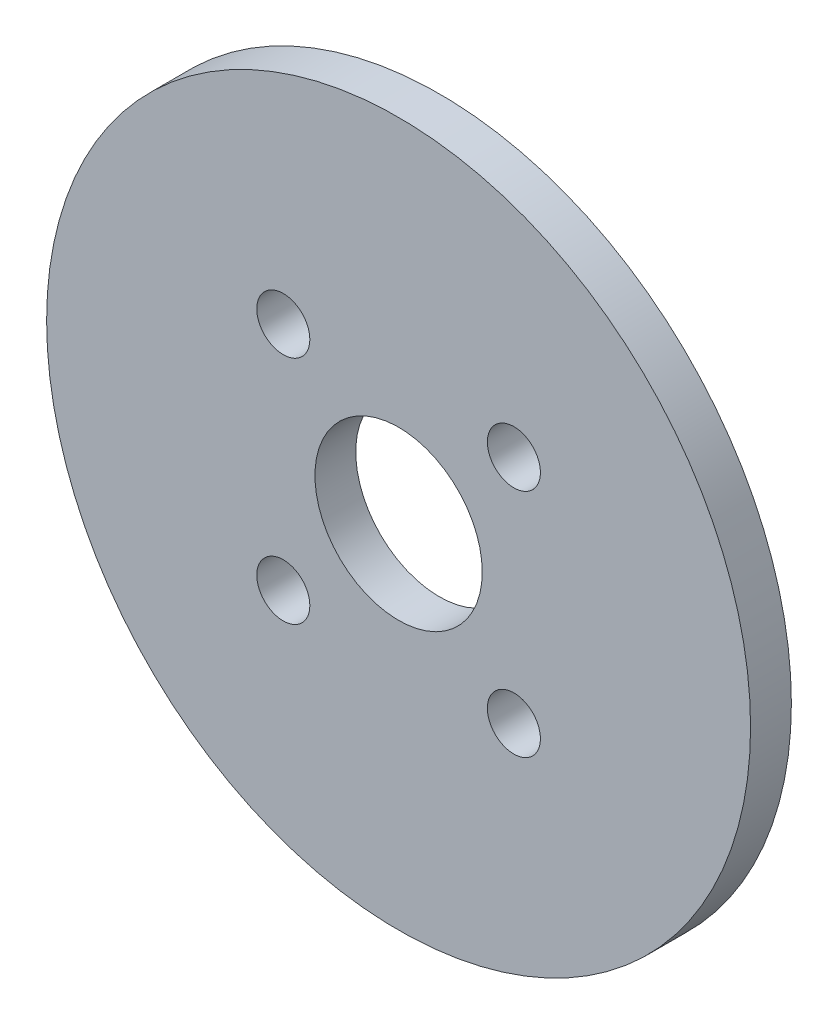
from build123d import *

# Parameters (mm, degrees)
SKETCH_1_R      = 17.25
SKETCH_1_R_2    = 1.3
SKETCH_1_R_3    = 4.1
EXTRUDE_1_DEPTH = 2


with BuildPart() as part:
    # 草图1 → 凸台-拉伸1 (new body)
    with BuildSketch(Plane.XY):
        Circle(SKETCH_1_R)
        with Locations((5.65, 5.65)):
            Circle(SKETCH_1_R_2, mode=Mode.SUBTRACT)
        with Locations((5.65, -5.65)):
            Circle(SKETCH_1_R_2, mode=Mode.SUBTRACT)
        with Locations((-5.65, 5.65)):
            Circle(SKETCH_1_R_2, mode=Mode.SUBTRACT)
        with Locations((-5.65, -5.65)):
            Circle(SKETCH_1_R_2, mode=Mode.SUBTRACT)
        Circle(SKETCH_1_R_3, mode=Mode.SUBTRACT)
    extrude(amount=EXTRUDE_1_DEPTH)


solid = part.part
